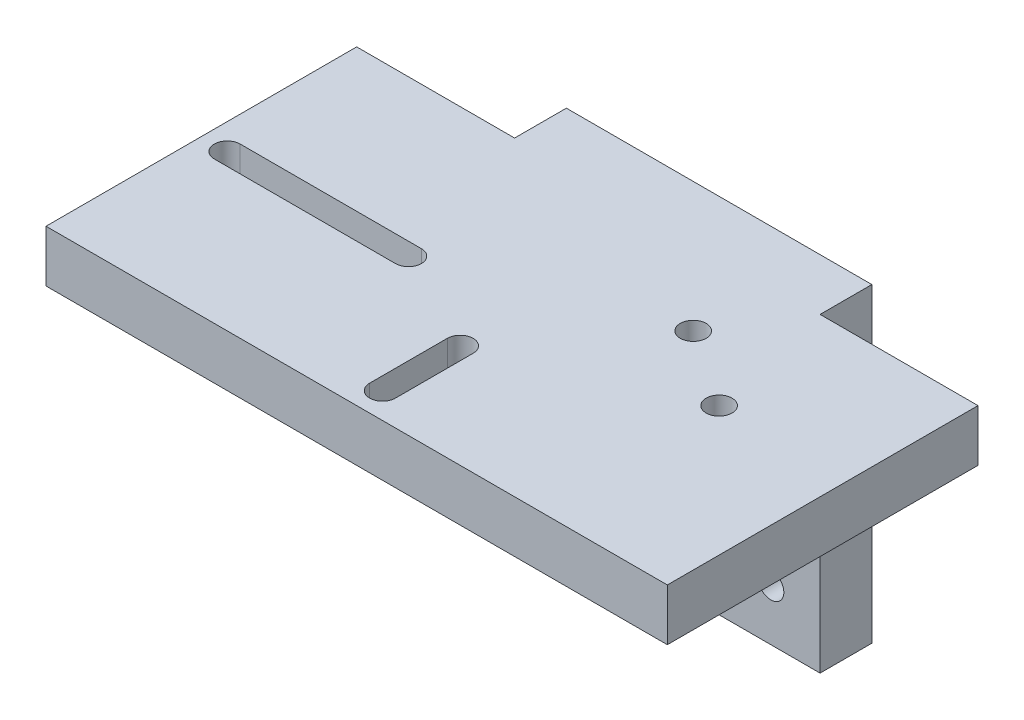
from build123d import *

# Parameters (mm, degrees)
SKETCH1_R           = 2.5
BOSS_EXTRUDE1_DEPTH = 10
SKETCH2_W           = 120
SKETCH2_H           = 60
SKETCH2_R           = 2.5
BOSS_EXTRUDE2_DEPTH = 10
BOSS_EXTRUDE3_DEPTH = 10


with BuildPart() as part:
    # Sketch1 → Boss-Extrude1 (new body)
    with BuildSketch(Plane.XY):
        Polygon((-29.5, 25), (-29.5, 35), (29.5, 35), (29.5, 25), (29.5, -25), (-29.5, -25), align=None)
        with Locations((-20, 15)):
            Circle(SKETCH1_R, mode=Mode.SUBTRACT)
        with Locations((20, 15)):
            Circle(SKETCH1_R, mode=Mode.SUBTRACT)
        with Locations((20, -15)):
            Circle(SKETCH1_R, mode=Mode.SUBTRACT)
        with Locations((-20, -15)):
            Circle(SKETCH1_R, mode=Mode.SUBTRACT)
    extrude(amount=BOSS_EXTRUDE1_DEPTH)

    # Sketch2 → Boss-Extrude2 (add)
    with BuildSketch(Plane(origin=(0, 35, 0), x_dir=(1, 0, 0), z_dir=(0, 1, 0))):
        with Locations((0, -40)):
            Rectangle(SKETCH2_W, SKETCH2_H)
        with Locations((20, -25)):
            Circle(SKETCH2_R, mode=Mode.SUBTRACT)
        with Locations((35, -35)):
            Circle(SKETCH2_R, mode=Mode.SUBTRACT)
        with BuildLine():
            Line((-55, -37.5), (-20, -37.5))
            ThreePointArc((-20, -37.5), (-17.5, -40), (-20, -42.5))
            Line((-20, -42.5), (-55, -42.5))
            ThreePointArc((-55, -42.5), (-57.5, -40), (-55, -37.5))
        make_face(mode=Mode.SUBTRACT)
        with BuildLine():
            Line((-2.5, -65), (-2.5, -50))
            ThreePointArc((-2.5, -50), (0, -47.5), (2.5, -50))
            Line((2.5, -50), (2.5, -65))
            ThreePointArc((2.5, -65), (0, -67.5), (-2.5, -65))
        make_face(mode=Mode.SUBTRACT)
    extrude(amount=-BOSS_EXTRUDE2_DEPTH)

    # Sketch4 → Boss-Extrude3 (add)
    with BuildSketch(Plane(origin=(14.5, 0, 0), x_dir=(0, 0, -1), z_dir=(1, 0, 0))):
        Polygon((-40, 25), (-10, 25), (-10, -5), align=None)
    boss_extrude3 = extrude(amount=-BOSS_EXTRUDE3_DEPTH)

    # Mirror1: Boss-Extrude3 across plane
    add(boss_extrude3.mirror(Plane(origin=(0, 0, 0), x_dir=(0, 0, 1), z_dir=(1, 0, 0))))


solid = part.part
